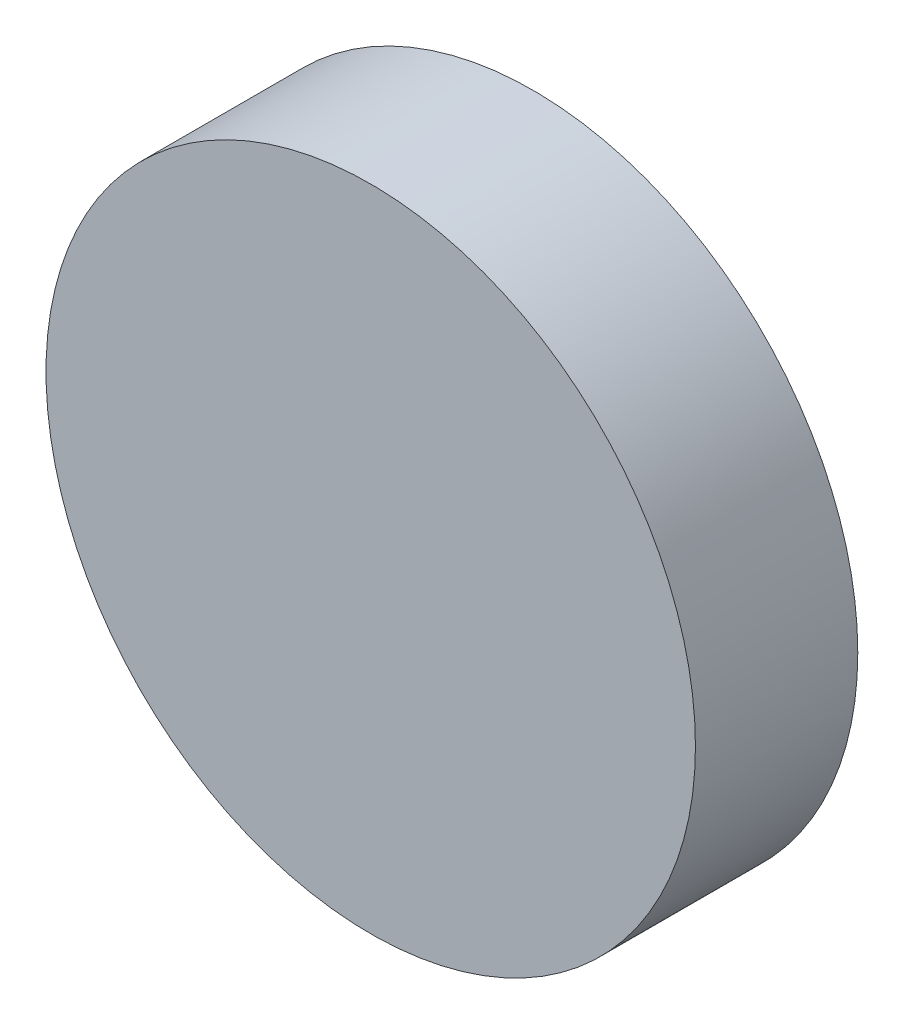
from build123d import *

# Parameters (mm, degrees)
SKETCH_1_R      = 0.8
EXTRUDE_1_DEPTH = 0.4


with BuildPart() as part:
    # Эскиз1 → Бобышка-Вытянуть1 (new body)
    with BuildSketch(Plane.XY):
        Circle(SKETCH_1_R)
    extrude(amount=EXTRUDE_1_DEPTH)


solid = part.part
